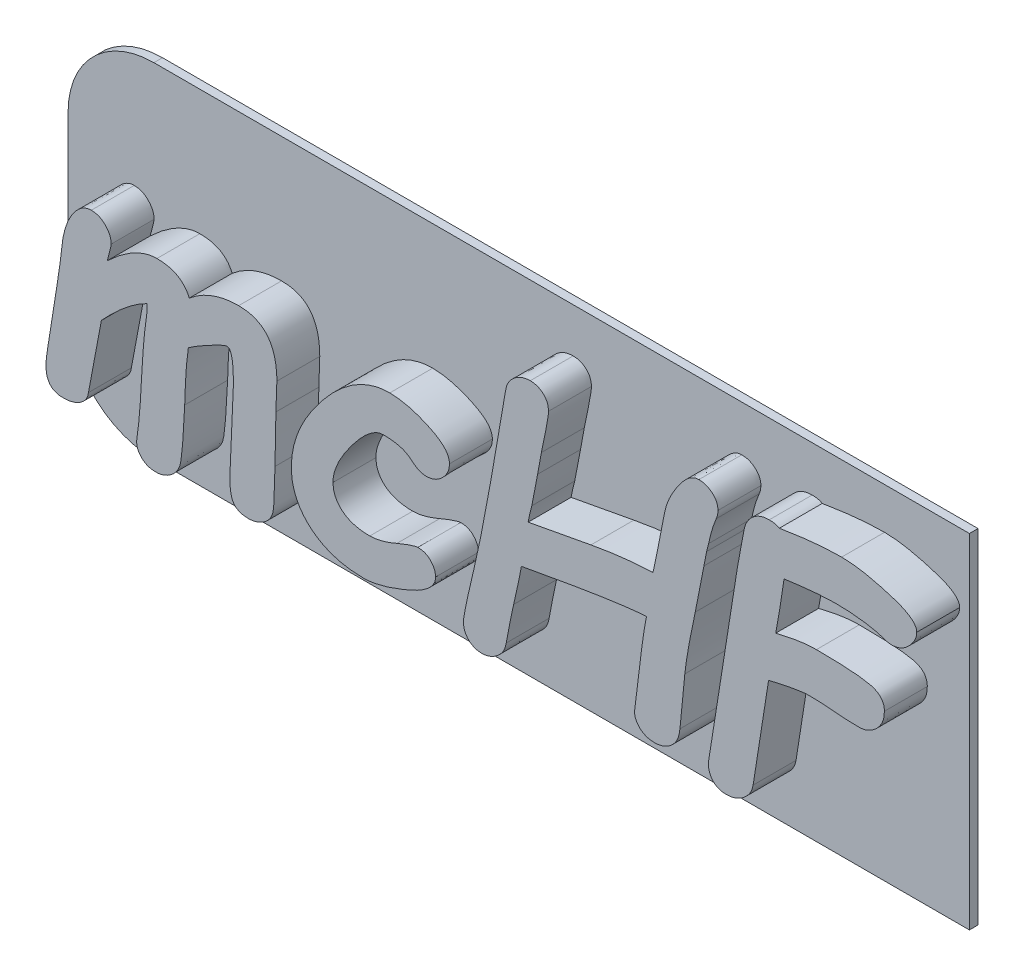
from build123d import *

# Parameters (mm, degrees)
SKETCH1_W    = 21
SKETCH1_H    = 8
BODY_DEPTH   = 0.2
TEXT_2_DEPTH = 1
FILLET1_R    = 2


with BuildPart() as part:
    # Sketch1 → body (new body)
    with BuildSketch(Plane.XY):
        Rectangle(SKETCH1_W, SKETCH1_H)
    extrude(amount=BODY_DEPTH)

    # Sketch2 → text 2 (add)
    with BuildSketch(Plane.XY.offset(0.2)):
        with BuildLine():
            add(Edge.make_bspline(
                [(-8.587596506, 0.459827581), (-8.533960483, 0.508991057), (-8.43066375, 0.603674183), (-8.274239511, 0.732043925), (-8.121054881, 0.838763403), (-7.974594097, 0.928339055), (-7.831709693, 0.996561661), (-7.694068236, 1.046427511), (-7.560444881, 1.077755316), (-7.472422593, 1.081915618), (-7.429793073, 1.083930467)],
                knots=[0, 0, 0, 0, 0.000218264, 0.000420351, 0.000606484, 0.00077796, 0.000934833, 0.00108056, 0.001216656, 0.001344467, 0.001344467, 0.001344467, 0.001344467], degree=3))
            add(Edge.make_bspline(
                [(-7.429793073, 1.083930467), (-7.383989491, 1.082729946), (-7.295919954, 1.080421626), (-7.16971868, 1.061434447), (-7.05633209, 1.02669725), (-6.953560386, 0.982440534), (-6.86544644, 0.920366349), (-6.787492259, 0.84833895), (-6.723473325, 0.760706647), (-6.692106256, 0.694936391), (-6.676077197, 0.661326768)],
                knots=[0, 0, 0, 0, 0.000137393, 0.000264174, 0.000381331, 0.000492476, 0.000598217, 0.000703005, 0.000809751, 0.000921306, 0.000921306, 0.000921306, 0.000921306], degree=3))
            add(Edge.make_bspline(
                [(-6.676077197, 0.661326768), (-6.6337414, 0.69503646), (-6.550350382, 0.76143619), (-6.417813418, 0.84841653), (-6.279663894, 0.919839221), (-6.138144648, 0.980811584), (-5.991088758, 1.025905541), (-5.840196861, 1.060523991), (-5.684348169, 1.080104581), (-5.578956204, 1.082649342), (-5.525898057, 1.083930467)],
                knots=[0, 0, 0, 0, 0.000162303, 0.000319697, 0.000474622, 0.000628367, 0.000781319, 0.000935372, 0.001092354, 0.00125151, 0.00125151, 0.00125151, 0.00125151], degree=3))
            add(Edge.make_bspline(
                [(-5.525898057, 1.083930467), (-5.489927694, 1.083029438), (-5.420319687, 1.081285811), (-5.318752211, 1.069654615), (-5.224707593, 1.047860251), (-5.136950689, 1.018251163), (-5.056586884, 0.98019667), (-4.982515924, 0.934462522), (-4.916610303, 0.878711846), (-4.856298127, 0.81573942), (-4.803732338, 0.743103659), (-4.7593999, 0.661854118), (-4.721061237, 0.572911514), (-4.689356842, 0.475648367), (-4.666027545, 0.369756795), (-4.648720706, 0.255878389), (-4.637452402, 0.133660659), (-4.636517037, 0.049230946), (-4.636034082, 0.005637523)],
                knots=[0, 0, 0, 0, 0.000107917, 0.000208836, 0.000306067, 0.000396999, 0.000486159, 0.000572288, 0.000657356, 0.000744415, 0.000833303, 0.000925447, 0.001021554, 0.001123508, 0.001231842, 0.00134645, 0.001468924, 0.001599667, 0.001599667, 0.001599667, 0.001599667], degree=3))
            add(Edge.make_bspline(
                [(-4.636034082, 0.005637523), (-4.636191976, -0.037570478), (-4.63653172, -0.130541585), (-4.641628325, -0.279025094), (-4.647744076, -0.446436146), (-4.65433711, -0.564015743), (-4.657817778, -0.626089656)],
                knots=[0, 0, 0, 0, 0.000129618, 0.000278899, 0.000445673, 0.000632181, 0.000632181, 0.000632181, 0.000632181], degree=3))
            add(Edge.make_bspline(
                [(-4.657817778, -0.626089656), (-4.658176975, -0.63661856), (-4.659254568, -0.668205272), (-4.661590874, -0.730636493), (-4.663554631, -0.823590263), (-4.665452143, -0.947042609), (-4.66911256, -1.101329509), (-4.672221671, -1.286131831), (-4.675244293, -1.501437086), (-4.678084162, -1.655007271), (-4.679601474, -1.737058144)],
                knots=[0, 0, 0, 0, 3.1605e-05, 9.4815e-05, 0.000187422, 0.000310519, 0.000465218, 0.000650408, 0.000865002, 0.001111196, 0.001111196, 0.001111196, 0.001111196], degree=3))
            add(Edge.make_bspline(
                [(-4.679601474, -1.737058144), (-4.680675305, -1.782441181), (-4.682745698, -1.869941631), (-4.685991929, -1.996651404), (-4.68938494, -2.114278776), (-4.692172696, -2.222866292), (-4.696886792, -2.321957742), (-4.701083842, -2.41164111), (-4.705711103, -2.492231461), (-4.710164913, -2.585283224), (-4.724850996, -2.689233971), (-4.763964694, -2.800726063), (-4.826637447, -2.894955207), (-4.909164587, -2.969092441), (-5.001657998, -3.025919328), (-5.09761088, -3.068047377), (-5.19680106, -3.093062485), (-5.263632276, -3.096709169), (-5.29716925, -3.098539133)],
                knots=[0, 0, 0, 0, 0.000136187, 0.000262575, 0.000380252, 0.00048922, 0.000588431, 0.000677851, 0.000758568, 0.000830586, 0.000957367, 0.001072105, 0.001182064, 0.001293064, 0.001402168, 0.001506571, 0.001606426, 0.001707009, 0.001707009, 0.001707009, 0.001707009], degree=3))
            add(Edge.make_bspline(
                [(-5.29716925, -3.098539133), (-5.333624176, -3.097390971), (-5.402008725, -3.095237172), (-5.496475267, -3.071396463), (-5.574530102, -3.03170334), (-5.638362057, -2.974082138), (-5.6824391, -2.890550477), (-5.711034713, -2.782159585), (-5.728629262, -2.646359146), (-5.730651295, -2.546383501), (-5.731753982, -2.491863204)],
                knots=[0, 0, 0, 0, 0.000109185, 0.000204816, 0.000289584, 0.000369741, 0.000458501, 0.000568466, 0.000704788, 0.000868296, 0.000868296, 0.000868296, 0.000868296], degree=3))
            Line((-5.731753982, -2.491863204), (-5.646797569, -0.537865688))
            add(Edge.make_bspline(
                [(-5.646797569, -0.537865688), (-5.647203088, -0.485943058), (-5.647963456, -0.388585701), (-5.653736042, -0.252969324), (-5.66554791, -0.138020041), (-5.681046298, -0.043976331), (-5.700989796, 0.030107313), (-5.724441385, 0.083652563), (-5.755147454, 0.120875295), (-5.781594636, 0.126234522), (-5.793837516, 0.128715405)],
                knots=[0, 0, 0, 0, 0.000155769, 0.000292074, 0.000407064, 0.000502148, 0.000578001, 0.000635974, 0.00067834, 0.000714856, 0.000714856, 0.000714856, 0.000714856], degree=3))
            add(Edge.make_bspline(
                [(-5.793837516, 0.128715405), (-5.801498336, 0.127813118), (-5.820023246, 0.125631266), (-5.852026364, 0.115859962), (-5.892877685, 0.100916957), (-5.942047562, 0.07804128), (-6.000971138, 0.051450134), (-6.068066229, 0.017114289), (-6.144680823, -0.021749803), (-6.226610938, -0.066605896), (-6.309808094, -0.111231357), (-6.38742793, -0.155585303), (-6.458480286, -0.195196271), (-6.52081654, -0.233406164), (-6.576391518, -0.267300096), (-6.623340618, -0.29856223), (-6.663720849, -0.325950923), (-6.68705516, -0.344236518), (-6.697860893, -0.352704273)],
                knots=[0, 0, 0, 0, 2.3105e-05, 5.5871e-05, 9.998e-05, 0.000153616, 0.000218429, 0.00029393, 0.000379664, 0.000476154, 0.00057412, 0.00066288, 0.000744344, 0.000818128, 0.000882205, 0.000939602, 0.00098734, 0.001028513, 0.001028513, 0.001028513, 0.001028513], degree=3))
            add(Edge.make_bspline(
                [(-6.697860893, -0.352704273), (-6.702813952, -0.381714877), (-6.713740028, -0.44571009), (-6.725994969, -0.550803657), (-6.738175565, -0.673522005), (-6.748391963, -0.814124699), (-6.7600417, -0.972700867), (-6.767627416, -1.149260444), (-6.777273931, -1.343070097), (-6.780917597, -1.478184295), (-6.782817306, -1.548629175)],
                knots=[0, 0, 0, 0, 8.8278e-05, 0.000194734, 0.00031731, 0.000458236, 0.00061763, 0.000794293, 0.000988363, 0.001199766, 0.001199766, 0.001199766, 0.001199766], degree=3))
            add(Edge.make_bspline(
                [(-6.782817306, -1.548629175), (-6.787101863, -1.636856121), (-6.795196146, -1.803532353), (-6.80771807, -2.038862937), (-6.822234269, -2.244680805), (-6.835624582, -2.421250285), (-6.851015639, -2.568276325), (-6.865573052, -2.686487329), (-6.880888937, -2.775366773), (-6.901736736, -2.854702479), (-6.937674171, -2.928899108), (-6.987416191, -3.006216146), (-7.050130497, -3.073746394), (-7.122025444, -3.131733589), (-7.201178225, -3.178233709), (-7.284209095, -3.212814346), (-7.370602497, -3.234436641), (-7.429671937, -3.23678222), (-7.459201062, -3.237954787)],
                knots=[0, 0, 0, 0, 0.000264994, 0.000500621, 0.000706963, 0.000883979, 0.001031807, 0.001150423, 0.001241218, 0.001302261, 0.00139583, 0.001487062, 0.001577254, 0.001670981, 0.00176326, 0.001851652, 0.001940151, 0.002028617, 0.002028617, 0.002028617, 0.002028617], degree=3))
            add(Edge.make_bspline(
                [(-7.459201062, -3.237954787), (-7.490910859, -3.236516366), (-7.551875278, -3.233750896), (-7.638789715, -3.211879802), (-7.715495972, -3.173784432), (-7.782117577, -3.122949385), (-7.834913024, -3.060531035), (-7.875839605, -2.992239846), (-7.899207313, -2.916666113), (-7.902120155, -2.864513162), (-7.903588457, -2.838223968)],
                knots=[0, 0, 0, 0, 9.5065e-05, 0.00018277, 0.000266552, 0.000350427, 0.000432297, 0.000510385, 0.000587901, 0.000666692, 0.000666692, 0.000666692, 0.000666692], degree=3))
            Line((-7.903588457, -2.838223968), (-7.852396772, -2.430868856))
            add(Edge.make_bspline(
                [(-7.852396772, -2.430868856), (-7.849885494, -2.406177903), (-7.844493742, -2.353166059), (-7.835191178, -2.268330015), (-7.828107105, -2.172027501), (-7.820506404, -2.065287534), (-7.812802216, -1.947657425), (-7.805266794, -1.819489961), (-7.797629926, -1.680073563), (-7.792812338, -1.583485277), (-7.790313239, -1.533380588)],
                knots=[0, 0, 0, 0, 7.4456e-05, 0.000159858, 0.000256009, 0.000364108, 0.000480899, 0.000609649, 0.000749273, 0.000899774, 0.000899774, 0.000899774, 0.000899774], degree=3))
            add(Edge.make_bspline(
                [(-7.790313239, -1.533380588), (-7.786367384, -1.463307202), (-7.778801686, -1.328949965), (-7.767139855, -1.135387263), (-7.753911658, -0.958604328), (-7.740843034, -0.797764718), (-7.727945574, -0.653240513), (-7.714872013, -0.525076484), (-7.702388104, -0.413101522), (-7.691769246, -0.34432561), (-7.686840684, -0.312404436)],
                knots=[0, 0, 0, 0, 0.000210554, 0.000403711, 0.000581729, 0.000742372, 0.000887822, 0.001017008, 0.001128872, 0.00122576, 0.00122576, 0.00122576, 0.00122576], degree=3))
            add(Edge.make_bspline(
                [(-7.686840684, -0.312404436), (-7.681462141, -0.276498825), (-7.671218037, -0.208112118), (-7.661237987, -0.110396952), (-7.657031926, -0.022656168), (-7.660267785, 0.032147294), (-7.661789433, 0.057918393)],
                knots=[0, 0, 0, 0, 0.000108902, 0.000207418, 0.000294614, 0.000372015, 0.000372015, 0.000372015, 0.000372015], degree=3))
            add(Edge.make_bspline(
                [(-7.661789433, 0.057918393), (-7.703153497, 0.036362385), (-7.788666315, -0.008200814), (-7.913959189, -0.088671696), (-8.043493559, -0.179195829), (-8.174388167, -0.282949881), (-8.308767474, -0.397403105), (-8.445220181, -0.524404098), (-8.584113913, -0.663762995), (-8.676433831, -0.761998134), (-8.723744605, -0.812340255)],
                knots=[0, 0, 0, 0, 0.000139866, 0.000289148, 0.000446281, 0.000613839, 0.000789984, 0.000975724, 0.001172888, 0.001380134, 0.001380134, 0.001380134, 0.001380134], degree=3))
            Line((-8.723744605, -0.812340255), (-9.025448793, -2.419977008))
            add(Edge.make_bspline(
                [(-9.025448793, -2.419977008), (-9.030493929, -2.449115289), (-9.040495819, -2.5068814), (-9.081954182, -2.5856556), (-9.140632523, -2.654984549), (-9.215753477, -2.713905359), (-9.303840453, -2.761653401), (-9.402225532, -2.79509186), (-9.508483144, -2.816529877), (-9.582277751, -2.818630131), (-9.620143689, -2.819707827)],
                knots=[0, 0, 0, 0, 8.8251e-05, 0.000174956, 0.000263092, 0.0003592, 0.0004596, 0.00056225, 0.000669908, 0.000783372, 0.000783372, 0.000783372, 0.000783372], degree=3))
            add(Edge.make_bspline(
                [(-9.620143689, -2.819707827), (-9.651191974, -2.818891048), (-9.709819278, -2.817348757), (-9.79129835, -2.79416869), (-9.86191805, -2.760363166), (-9.918222264, -2.708440645), (-9.96251898, -2.644227488), (-9.992872452, -2.565167575), (-10.010968768, -2.473078996), (-10.01323183, -2.406997911), (-10.014428584, -2.372052877)],
                knots=[0, 0, 0, 0, 9.2811e-05, 0.000175252, 0.000252215, 0.000325482, 0.000402221, 0.000484338, 0.000577684, 0.00068245, 0.00068245, 0.00068245, 0.00068245], degree=3))
            add(Edge.make_bspline(
                [(-10.014428584, -2.372052877), (-10.014137184, -2.344434752), (-10.013514733, -2.285440474), (-10.003151162, -2.192975658), (-9.992264213, -2.090276149), (-9.979675456, -2.019456033), (-9.973039562, -1.982124722)],
                knots=[0, 0, 0, 0, 8.2807e-05, 0.000176881, 0.000278881, 0.000392585, 0.000392585, 0.000392585, 0.000392585], degree=3))
            Line((-9.973039562, -1.982124722), (-9.763916082, -0.657676015))
            add(Edge.make_bspline(
                [(-9.763916082, -0.657676015), (-9.751379334, -0.577831014), (-9.727405732, -0.425146092), (-9.696220448, -0.206881727), (-9.669067685, -0.010250763), (-9.655804959, 0.113795749), (-9.649551678, 0.172282796)],
                knots=[0, 0, 0, 0, 0.000242465, 0.000463658, 0.000661447, 0.000837898, 0.000837898, 0.000837898, 0.000837898], degree=3))
            add(Edge.make_bspline(
                [(-9.649551678, 0.172282796), (-9.645159982, 0.21407405), (-9.636544565, 0.296058115), (-9.61838704, 0.415412642), (-9.594481675, 0.528189962), (-9.564882624, 0.633880281), (-9.531486693, 0.73296028), (-9.493082495, 0.825484323), (-9.449899546, 0.911126873), (-9.401978173, 0.989692979), (-9.350849347, 1.059891619), (-9.299523135, 1.122544047), (-9.244828518, 1.173937856), (-9.19136428, 1.218407532), (-9.134451522, 1.251538408), (-9.077039271, 1.275584093), (-9.018239504, 1.290782948), (-8.97870089, 1.292298914), (-8.95900852, 1.293053947)],
                knots=[0, 0, 0, 0, 0.000126054, 0.000247287, 0.000362003, 0.000471671, 0.00057638, 0.000675496, 0.000771942, 0.000863848, 0.000951214, 0.001032378, 0.00110633, 0.001176072, 0.001240519, 0.001303021, 0.001362459, 0.001421436, 0.001421436, 0.001421436, 0.001421436], degree=3))
            add(Edge.make_bspline(
                [(-8.95900852, 1.293053947), (-8.927586332, 1.2914853), (-8.866126653, 1.288417133), (-8.778097864, 1.261046661), (-8.69794561, 1.216603189), (-8.628418232, 1.155478918), (-8.570323632, 1.085262299), (-8.527495956, 1.008213207), (-8.501255669, 0.926223779), (-8.4978286, 0.869547251), (-8.496104984, 0.841042259)],
                knots=[0, 0, 0, 0, 9.4074e-05, 0.000184003, 0.000273714, 0.000367162, 0.000460043, 0.00054584, 0.000630243, 0.000715645, 0.000715645, 0.000715645, 0.000715645], degree=3))
            add(Edge.make_bspline(
                [(-8.496104984, 0.841042259), (-8.49635826, 0.835583955), (-8.497004848, 0.821649443), (-8.502181922, 0.796270225), (-8.509711505, 0.762224464), (-8.519561836, 0.718928389), (-8.532884492, 0.667163761), (-8.547976196, 0.605674433), (-8.566296238, 0.535543067), (-8.580249307, 0.485944473), (-8.587596506, 0.459827581)],
                knots=[0, 0, 0, 0, 1.6374e-05, 4.1801e-05, 7.7479e-05, 0.000121074, 0.000174964, 0.000237835, 0.000311014, 0.000392404, 0.000392404, 0.000392404, 0.000392404], degree=3))
        make_face()
        with BuildLine():
            add(Edge.make_bspline(
                [(-4.298386796, -1.555164283), (-4.295965927, -1.48603896), (-4.291069107, -1.346215528), (-4.254162554, -1.135685081), (-4.196302677, -0.92223845), (-4.113926679, -0.70605603), (-4.007088169, -0.488283843), (-3.87899783, -0.267120041), (-3.726953918, -0.043861526), (-3.55489563, 0.176649019), (-3.371595514, 0.385805122), (-3.182707998, 0.571802238), (-2.990932895, 0.728957626), (-2.798335307, 0.858794732), (-2.602814257, 0.959452302), (-2.405263507, 1.030921842), (-2.205517902, 1.075618212), (-2.071224938, 1.081173095), (-2.004563625, 1.083930467)],
                knots=[0, 0, 0, 0, 0.000207292, 0.0004193, 0.000639396, 0.000870007, 0.001112113, 0.001366369, 0.00163614, 0.001921768, 0.002204975, 0.002469931, 0.002716082, 0.002947782, 0.003165524, 0.003373968, 0.0035767, 0.003776523, 0.003776523, 0.003776523, 0.003776523], degree=3))
            add(Edge.make_bspline(
                [(-2.004563625, 1.083930467), (-1.934675719, 1.080929956), (-1.790141105, 1.074724623), (-1.569121355, 1.03079922), (-1.338361007, 0.960374449), (-1.144879424, 0.880083257), (-0.993601053, 0.807726787), (-0.893621012, 0.748350498), (-0.808419089, 0.688199819), (-0.738201859, 0.625317406), (-0.682640449, 0.560325145), (-0.644043607, 0.491798866), (-0.619031884, 0.421230603), (-0.616186246, 0.372892786), (-0.614763831, 0.348730733)],
                knots=[0, 0, 0, 0, 0.000209602, 0.000433477, 0.000673634, 0.00093253, 0.001061128, 0.001176381, 0.001280965, 0.001373501, 0.001458569, 0.001536116, 0.001608446, 0.001680736, 0.001680736, 0.001680736, 0.001680736], degree=3))
            add(Edge.make_bspline(
                [(-0.614763831, 0.348730733), (-0.61653233, 0.316523197), (-0.620071024, 0.252077272), (-0.653014375, 0.158275098), (-0.705135837, 0.068858543), (-0.776600759, -0.012561058), (-0.859032283, -0.084982745), (-0.954433633, -0.135235983), (-1.055759562, -0.169306924), (-1.126765539, -0.172477046), (-1.162623781, -0.174077967)],
                knots=[0, 0, 0, 0, 9.6348e-05, 0.000192789, 0.000294789, 0.000405249, 0.000516538, 0.000621806, 0.000726871, 0.000834061, 0.000834061, 0.000834061, 0.000834061], degree=3))
            add(Edge.make_bspline(
                [(-1.162623781, -0.174077967), (-1.190808921, -0.171630087), (-1.249760746, -0.166510118), (-1.338430513, -0.133790615), (-1.428278462, -0.079962863), (-1.485258284, -0.033302627), (-1.515519653, -0.008521879)],
                knots=[0, 0, 0, 0, 8.4572e-05, 0.000176889, 0.000280379, 0.000397592, 0.000397592, 0.000397592, 0.000397592], degree=3))
            add(Edge.make_bspline(
                [(-1.515519653, -0.008521879), (-1.532620552, 0.005367968), (-1.5680624, 0.034154869), (-1.629049221, 0.069389399), (-1.697777202, 0.099258376), (-1.774364145, 0.122378563), (-1.858201926, 0.14268162), (-1.95057968, 0.154590966), (-2.050109758, 0.164156214), (-2.119263707, 0.164487779), (-2.154871126, 0.164658503)],
                knots=[0, 0, 0, 0, 6.601e-05, 0.000136807, 0.000210462, 0.000290382, 0.00037651, 0.000468931, 0.000569514, 0.000676276, 0.000676276, 0.000676276, 0.000676276], degree=3))
            add(Edge.make_bspline(
                [(-2.154871126, 0.164658503), (-2.180509361, 0.162918905), (-2.234226275, 0.15927412), (-2.315461298, 0.128894516), (-2.400287518, 0.082440708), (-2.490513139, 0.018003161), (-2.583936562, -0.06505867), (-2.683000662, -0.165392206), (-2.785490877, -0.284247623), (-2.89019214, -0.416486566), (-2.990141574, -0.554583988), (-3.07975361, -0.690753372), (-3.156171065, -0.820514593), (-3.21823319, -0.944930397), (-3.265928885, -1.063074516), (-3.301840133, -1.174904797), (-3.323983519, -1.281259651), (-3.32664076, -1.350666483), (-3.327923147, -1.384162271)],
                knots=[0, 0, 0, 0, 7.6739e-05, 0.000160783, 0.000257273, 0.000366669, 0.000492493, 0.000631896, 0.00078938, 0.000963056, 0.001137788, 0.001300617, 0.001451931, 0.001589294, 0.001717323, 0.001833758, 0.001941417, 0.002041835, 0.002041835, 0.002041835, 0.002041835], degree=3))
            add(Edge.make_bspline(
                [(-3.327923147, -1.384162271), (-3.325417729, -1.43027969), (-3.320529175, -1.520263668), (-3.275645198, -1.647775505), (-3.204102716, -1.761853684), (-3.104418576, -1.860495594), (-2.979189061, -1.940548115), (-2.828944274, -1.99513164), (-2.657573552, -2.030884302), (-2.535200245, -2.033904012), (-2.470734716, -2.035494777)],
                knots=[0, 0, 0, 0, 0.000137966, 0.000269198, 0.000400353, 0.000538984, 0.000686426, 0.000842591, 0.001016041, 0.001209135, 0.001209135, 0.001209135, 0.001209135], degree=3))
            add(Edge.make_bspline(
                [(-2.470734716, -2.035494777), (-2.426314273, -2.032923265), (-2.330795294, -2.027393646), (-2.180259831, -1.994926809), (-2.013754676, -1.941587926), (-1.899656196, -1.894094482), (-1.839007537, -1.868849503)],
                knots=[0, 0, 0, 0, 0.000133326, 0.000286696, 0.000460311, 0.000657309, 0.000657309, 0.000657309, 0.000657309], degree=3))
            add(Edge.make_bspline(
                [(-1.839007537, -1.868849503), (-1.807426063, -1.856129214), (-1.747577593, -1.832023631), (-1.662822244, -1.798116329), (-1.587470105, -1.769260139), (-1.521355476, -1.747165169), (-1.465470465, -1.727696008), (-1.418586441, -1.714633509), (-1.381123515, -1.706164592), (-1.359066202, -1.704903167), (-1.349963565, -1.7043826)],
                knots=[0, 0, 0, 0, 0.00010214, 0.00019356, 0.000273872, 0.000344139, 0.000402692, 0.000451317, 0.000490193, 0.00051751, 0.00051751, 0.00051751, 0.00051751], degree=3))
            add(Edge.make_bspline(
                [(-1.349963565, -1.7043826), (-1.321132502, -1.70580763), (-1.265486632, -1.708558034), (-1.185952519, -1.730993672), (-1.114569458, -1.768784058), (-1.053326278, -1.82136399), (-1.002728702, -1.882192742), (-0.965191029, -1.949617172), (-0.942895682, -2.022124585), (-0.939802613, -2.072379786), (-0.938251714, -2.09757831)],
                knots=[0, 0, 0, 0, 8.6383e-05, 0.000166724, 0.000245658, 0.000326823, 0.00040729, 0.000481873, 0.000556987, 0.000632527, 0.000632527, 0.000632527, 0.000632527], degree=3))
            add(Edge.make_bspline(
                [(-0.938251714, -2.09757831), (-0.940139806, -2.123645874), (-0.94401688, -2.177173893), (-0.977459419, -2.255354333), (-1.030194231, -2.330881238), (-1.1025541, -2.405917016), (-1.196172339, -2.477407457), (-1.308063582, -2.550382347), (-1.44192803, -2.618521181), (-1.58996003, -2.686143851), (-1.743993818, -2.748574225), (-1.894003116, -2.80342571), (-2.034608388, -2.852885947), (-2.167420472, -2.889862539), (-2.290827406, -2.922033595), (-2.406411305, -2.941844087), (-2.513213379, -2.956359215), (-2.58178886, -2.958230612), (-2.614507108, -2.95912348)],
                knots=[0, 0, 0, 0, 7.7951e-05, 0.000160067, 0.000250999, 0.000353458, 0.000471342, 0.000603668, 0.000753722, 0.000921386, 0.001091891, 0.001252135, 0.001400588, 0.001538829, 0.001665629, 0.001782922, 0.00189046, 0.001988583, 0.001988583, 0.001988583, 0.001988583], degree=3))
            add(Edge.make_bspline(
                [(-2.614507108, -2.95912348), (-2.676263569, -2.957719996), (-2.79711984, -2.954973404), (-2.974194083, -2.937846362), (-3.141759405, -2.907531579), (-3.299931826, -2.864921262), (-3.448651306, -2.810286022), (-3.588926743, -2.744222196), (-3.71860738, -2.664021276), (-3.838512285, -2.573936287), (-3.946739232, -2.473993621), (-4.040278511, -2.364599519), (-4.121124856, -2.248792996), (-4.18520625, -2.12418382), (-4.237233125, -1.993147264), (-4.27301472, -1.853740107), (-4.293663601, -1.706819166), (-4.29679041, -1.606421905), (-4.298386796, -1.555164283)],
                knots=[0, 0, 0, 0, 0.000185277, 0.000362583, 0.000533068, 0.000695561, 0.000853383, 0.001007821, 0.001159879, 0.001309969, 0.00145717, 0.001600827, 0.001741011, 0.001879855, 0.002020225, 0.002163145, 0.002310555, 0.002464319, 0.002464319, 0.002464319, 0.002464319], degree=3))
        make_face()
        with BuildLine():
            add(Edge.make_bspline(
                [(3.976150067, -0.437660687), (3.946376338, -0.439421191), (3.882802102, -0.443180301), (3.781024064, -0.450402592), (3.667150501, -0.463164709), (3.540451709, -0.477354642), (3.401211646, -0.493000491), (3.2500253, -0.514632224), (3.086520761, -0.536968872), (2.910842242, -0.563453736), (2.722393012, -0.592753682), (2.521722946, -0.625708884), (2.308389815, -0.660014458), (2.08318489, -0.700015492), (1.845323235, -0.741070633), (1.594641726, -0.784423857), (1.332338243, -0.832689135), (1.152987784, -0.865373862), (1.061491564, -0.882048082)],
                knots=[0, 0, 0, 0, 8.9479e-05, 0.00019106, 0.00030605, 0.000433186, 0.000573556, 0.000726361, 0.000891332, 0.001068628, 0.001259338, 0.001463469, 0.001678701, 0.001907547, 0.002149642, 0.002402842, 0.002670746, 0.002949756, 0.002949756, 0.002949756, 0.002949756], degree=3))
            add(Edge.make_bspline(
                [(1.061491564, -0.882048082), (1.056830823, -0.908562428), (1.047053906, -0.964182036), (1.030414389, -1.051625099), (1.012365351, -1.147279921), (0.99013956, -1.250593537), (0.966162826, -1.362049149), (0.940046957, -1.481502129), (0.912026371, -1.609089679), (0.89134234, -1.696424197), (0.880686889, -1.741414883)],
                knots=[0, 0, 0, 0, 8.0761e-05, 0.000169415, 0.000267035, 0.000372776, 0.000486427, 0.000609056, 0.000739599, 0.000878303, 0.000878303, 0.000878303, 0.000878303], degree=3))
            add(Edge.make_bspline(
                [(0.880686889, -1.741414883), (0.870505288, -1.789698944), (0.850905992, -1.882644406), (0.822907314, -2.016678812), (0.795656116, -2.139748291), (0.775047735, -2.253477132), (0.753689086, -2.355951129), (0.736563116, -2.448296922), (0.720774724, -2.529827166), (0.712474039, -2.581155959), (0.708595691, -2.605138423)],
                knots=[0, 0, 0, 0, 0.000148037, 0.000284967, 0.00041079, 0.000526141, 0.000631663, 0.000724799, 0.000807899, 0.000880777, 0.000880777, 0.000880777, 0.000880777], degree=3))
            add(Edge.make_bspline(
                [(0.708595691, -2.605138423), (0.701871058, -2.639256399), (0.688687698, -2.706143248), (0.646933121, -2.800681939), (0.585753891, -2.884754555), (0.50993739, -2.958930332), (0.42431047, -3.020916868), (0.331032544, -3.064633685), (0.234378, -3.093889915), (0.16784028, -3.096990136), (0.134595306, -3.098539133)],
                knots=[0, 0, 0, 0, 0.00010409, 0.000204064, 0.000307128, 0.000414185, 0.000521175, 0.00062251, 0.000722151, 0.000821649, 0.000821649, 0.000821649, 0.000821649], degree=3))
            add(Edge.make_bspline(
                [(0.134595306, -3.098539133), (0.104652231, -3.097223001), (0.046722138, -3.094676714), (-0.035387848, -3.0707688), (-0.109173418, -3.03339073), (-0.172527514, -2.98067678), (-0.222860209, -2.916614201), (-0.261556581, -2.845514041), (-0.283585927, -2.766529496), (-0.286511296, -2.711646716), (-0.288008393, -2.683559728)],
                knots=[0, 0, 0, 0, 8.9638e-05, 0.00017342, 0.000254284, 0.000336285, 0.000418444, 0.000497378, 0.00057772, 0.000661933, 0.000661933, 0.000661933, 0.000661933], degree=3))
            add(Edge.make_bspline(
                [(-0.288008393, -2.683559728), (-0.287251203, -2.665010169), (-0.285370526, -2.618937587), (-0.27093055, -2.537147999), (-0.253672087, -2.428276728), (-0.224895449, -2.29324107), (-0.19169387, -2.130777248), (-0.150417125, -1.941491397), (-0.099500051, -1.725821574), (-0.06395158, -1.572965382), (-0.045120184, -1.491991565)],
                knots=[0, 0, 0, 0, 5.5644e-05, 0.000138207, 0.000248688, 0.000386465, 0.000552229, 0.000746214, 0.000967616, 0.00121702, 0.00121702, 0.00121702, 0.00121702], degree=3))
            add(Edge.make_bspline(
                [(-0.045120184, -1.491991565), (-0.035663297, -1.452059311), (-0.015388833, -1.366449218), (0.016566501, -1.229811342), (0.048518334, -1.075551734), (0.084938801, -0.90472583), (0.122819295, -0.716241255), (0.163098943, -0.510741774), (0.205217838, -0.288046559), (0.251761968, -0.048710355), (0.297602564, 0.208656933), (0.348544549, 0.482485822), (0.398935195, 0.773935059), (0.453888632, 1.082022622), (0.510470281, 1.40770079), (0.568744095, 1.750586284), (0.631681599, 2.110110823), (0.672475817, 2.355703517), (0.693347104, 2.481354555)],
                knots=[0, 0, 0, 0, 0.000123112, 0.000263937, 0.00042095, 0.000595688, 0.000787935, 0.000997698, 0.001223916, 0.001467864, 0.001729144, 0.002008154, 0.002303437, 0.00261645, 0.002947005, 0.003295103, 0.003659856, 0.004041973, 0.004041973, 0.004041973, 0.004041973], degree=3))
            add(Edge.make_bspline(
                [(0.693347104, 2.481354555), (0.699621393, 2.514787613), (0.712000797, 2.580752276), (0.754299045, 2.672963323), (0.812370676, 2.756579817), (0.887044341, 2.828946542), (0.971611966, 2.889538546), (1.064773108, 2.934025478), (1.164165585, 2.96119678), (1.232687985, 2.964414316), (1.26734749, 2.966041787)],
                knots=[0, 0, 0, 0, 0.000101721, 0.000200699, 0.000301618, 0.000405593, 0.000511064, 0.0006124, 0.000713852, 0.000817691, 0.000817691, 0.000817691, 0.000817691], degree=3))
            add(Edge.make_bspline(
                [(1.26734749, 2.966041787), (1.296920088, 2.965081679), (1.354402513, 2.963215445), (1.435858205, 2.940258056), (1.510166953, 2.905271933), (1.573770325, 2.854509614), (1.627437263, 2.794665793), (1.665688545, 2.724194661), (1.689108915, 2.646214686), (1.691829169, 2.591164462), (1.693218743, 2.563043414)],
                knots=[0, 0, 0, 0, 8.8466e-05, 0.000171957, 0.000251847, 0.000333333, 0.00041438, 0.000491397, 0.000572041, 0.000656254, 0.000656254, 0.000656254, 0.000656254], degree=3))
            add(Edge.make_bspline(
                [(1.693218743, 2.563043414), (1.692693293, 2.548504851), (1.691401368, 2.512758886), (1.682567543, 2.449246746), (1.66971169, 2.365709907), (1.650350296, 2.261702678), (1.628154851, 2.136982997), (1.599353717, 1.99183951), (1.565786933, 1.826603236), (1.540842015, 1.709826062), (1.527662655, 1.648128189)],
                knots=[0, 0, 0, 0, 4.3622e-05, 0.000107253, 0.000192133, 0.000297249, 0.000424576, 0.00057218, 0.000741144, 0.000930412, 0.000930412, 0.000930412, 0.000930412], degree=3))
            Line((1.527662655, 1.648128189), (1.439438687, 1.164530142))
            add(Edge.make_bspline(
                [(1.439438687, 1.164530142), (1.427267128, 1.094428006), (1.404290623, 0.962094737), (1.369140329, 0.775163826), (1.336993884, 0.610935475), (1.314708237, 0.509169993), (1.304379773, 0.462005951)],
                knots=[0, 0, 0, 0, 0.00021345, 0.000402933, 0.000570615, 0.000715456, 0.000715456, 0.000715456, 0.000715456], degree=3))
            add(Edge.make_bspline(
                [(1.304379773, 0.462005951), (1.287190174, 0.397573716), (1.254246483, 0.274089989), (1.230688897, 0.148482615), (1.219423359, 0.088415567)],
                knots=[0, 0, 0, 0, 0.000199974, 0.000383249, 0.000383249, 0.000383249, 0.000383249], degree=3))
            Line((1.219423359, 0.088415567), (2.682198534, 0.360711765))
            add(Edge.make_bspline(
                [(2.682198534, 0.360711765), (2.805838254, 0.382832539), (3.050250908, 0.42656118), (3.415675367, 0.472939431), (3.773677058, 0.509743797), (4.010563511, 0.520805284), (4.127546753, 0.526267854)],
                knots=[0, 0, 0, 0, 0.000376746, 0.000744757, 0.00110479, 0.001456055, 0.001456055, 0.001456055, 0.001456055], degree=3))
            add(Edge.make_bspline(
                [(4.127546753, 0.526267854), (4.133494776, 0.551288614), (4.147331545, 0.609493913), (4.167235735, 0.710394564), (4.193465702, 0.8363537), (4.225709987, 0.98783453), (4.259661204, 1.165699711), (4.300404598, 1.368854077), (4.344875812, 1.597620537), (4.37590278, 1.758494762), (4.392218657, 1.843092267)],
                knots=[0, 0, 0, 0, 7.7148e-05, 0.000179467, 0.000308489, 0.000463145, 0.000644071, 0.000851697, 0.001084745, 0.001343215, 0.001343215, 0.001343215, 0.001343215], degree=3))
            add(Edge.make_bspline(
                [(4.392218657, 1.843092267), (4.403875239, 1.899027805), (4.428109146, 2.015317187), (4.494906278, 2.189936949), (4.587963121, 2.370500432), (4.681523747, 2.522909269), (4.765920869, 2.640047636), (4.829512159, 2.718660621), (4.892406239, 2.785046879), (4.954078256, 2.840355104), (5.01618863, 2.882458273), (5.076587691, 2.913578455), (5.137245788, 2.932193392), (5.17740661, 2.935171499), (5.197126218, 2.936633798)],
                knots=[0, 0, 0, 0, 0.000171196, 0.000355915, 0.00055855, 0.000780108, 0.000891657, 0.000991512, 0.001083192, 0.001165776, 0.001239488, 0.001307681, 0.001369025, 0.001428203, 0.001428203, 0.001428203, 0.001428203], degree=3))
            add(Edge.make_bspline(
                [(5.197126218, 2.936633798), (5.226669857, 2.935152941), (5.284419513, 2.932258276), (5.367813703, 2.909920993), (5.444142259, 2.872117699), (5.511741263, 2.820969381), (5.570129875, 2.761447613), (5.610960354, 2.691714251), (5.637893858, 2.616538205), (5.640298465, 2.563636455), (5.641513613, 2.536902979)],
                knots=[0, 0, 0, 0, 8.8553e-05, 0.000173096, 0.000256879, 0.000342489, 0.000426469, 0.000505109, 0.000583296, 0.000663171, 0.000663171, 0.000663171, 0.000663171], degree=3))
            add(Edge.make_bspline(
                [(5.641513613, 2.536902979), (5.639822714, 2.50534443), (5.636363211, 2.44077706), (5.613104396, 2.380419719), (5.601213776, 2.349563195)],
                knots=[0, 0, 0, 0, 9.4181e-05, 0.000192691, 0.000192691, 0.000192691, 0.000192691], degree=3))
            add(Edge.make_bspline(
                [(5.601213776, 2.349563195), (5.583493181, 2.306961999), (5.546712577, 2.218539589), (5.502718794, 2.076225469), (5.458993713, 1.922661652), (5.436434159, 1.814940758), (5.42476584, 1.759225038)],
                knots=[0, 0, 0, 0, 0.000138344, 0.000287144, 0.000446485, 0.000617196, 0.000617196, 0.000617196, 0.000617196], degree=3))
            add(Edge.make_bspline(
                [(5.42476584, 1.759225038), (5.418102838, 1.7301199), (5.403792578, 1.667610219), (5.386228028, 1.605933732), (5.376841709, 1.572974439)],
                knots=[0, 0, 0, 0, 8.9559e-05, 0.000192347, 0.000192347, 0.000192347, 0.000192347], degree=3))
            add(Edge.make_bspline(
                [(5.376841709, 1.572974439), (5.368385382, 1.533785648), (5.353290674, 1.463832903), (5.334779875, 1.371607358), (5.322303535, 1.304442575), (5.31687122, 1.268013394), (5.314758176, 1.253843295)],
                knots=[0, 0, 0, 0, 0.00012027, 0.000214684, 0.000282196, 0.000325174, 0.000325174, 0.000325174, 0.000325174], degree=3))
            add(Edge.make_bspline(
                [(5.314758176, 1.253843295), (5.311091111, 1.233518512), (5.30258069, 1.186349334), (5.289034317, 1.10550197), (5.268450203, 1.005616176), (5.246353522, 0.885950669), (5.218555567, 0.747006994), (5.187336608, 0.588639326), (5.15117104, 0.410782764), (5.125617548, 0.285918049), (5.112169805, 0.220206927)],
                knots=[0, 0, 0, 0, 6.1959e-05, 0.000143793, 0.000245898, 0.000367872, 0.000508853, 0.000670981, 0.00085212, 0.001053339, 0.001053339, 0.001053339, 0.001053339], degree=3))
            add(Edge.make_bspline(
                [(5.112169805, 0.220206927), (5.096151911, 0.143973193), (5.065273248, -0.002987182), (5.021399968, -0.215247894), (4.983260158, -0.411309939), (4.950453316, -0.590656236), (4.923412181, -0.75341088), (4.900016397, -0.899241944), (4.882582673, -1.028938312), (4.873508296, -1.110035426), (4.869281596, -1.147809171)],
                knots=[0, 0, 0, 0, 0.000233696, 0.000450509, 0.000650234, 0.000832896, 0.000997453, 0.001145185, 0.001275964, 0.001389991, 0.001389991, 0.001389991, 0.001389991], degree=3))
            Line((4.869281596, -1.147809171), (4.756006378, -2.313236898))
            add(Edge.make_bspline(
                [(4.756006378, -2.313236898), (4.750660405, -2.356394913), (4.740391831, -2.439293056), (4.700290932, -2.55527893), (4.640912665, -2.656388264), (4.562829686, -2.739867764), (4.473548191, -2.80691571), (4.374656944, -2.854339658), (4.268289325, -2.883897278), (4.194542995, -2.887552566), (4.156954742, -2.889415653)],
                knots=[0, 0, 0, 0, 0.000130179, 0.000250049, 0.000365302, 0.000479381, 0.000590696, 0.000698355, 0.000806684, 0.000919297, 0.000919297, 0.000919297, 0.000919297], degree=3))
            add(Edge.make_bspline(
                [(4.156954742, -2.889415653), (4.12487193, -2.888002093), (4.063172408, -2.885283629), (3.974709303, -2.862906833), (3.895312315, -2.825387041), (3.825640344, -2.774459807), (3.76947238, -2.712917093), (3.727748383, -2.644672688), (3.701100376, -2.570749497), (3.698582288, -2.518946259), (3.69731876, -2.492952389)],
                knots=[0, 0, 0, 0, 9.6151e-05, 0.000184911, 0.000271637, 0.000358122, 0.000442159, 0.000519866, 0.000597022, 0.000674729, 0.000674729, 0.000674729, 0.000674729], degree=3))
            Line((3.69731876, -2.492952389), (3.862874848, -1.145630802))
            add(Edge.make_bspline(
                [(3.862874848, -1.145630802), (3.866318712, -1.113658129), (3.872902609, -1.052533531), (3.885247198, -0.965479786), (3.896833654, -0.887347213), (3.90560766, -0.838462847), (3.909709795, -0.81560781)],
                knots=[0, 0, 0, 0, 9.6465e-05, 0.00018442, 0.000263751, 0.000333408, 0.000333408, 0.000333408, 0.000333408], degree=3))
            Line((3.909709795, -0.81560781), (3.943474523, -0.614108623))
            add(Edge.make_bspline(
                [(3.943474523, -0.614108623), (3.947761847, -0.583894176), (3.956173014, -0.524617401), (3.969577896, -0.466268229), (3.976150067, -0.437660687)],
                knots=[0, 0, 0, 0, 9.1504e-05, 0.00017952, 0.00017952, 0.00017952, 0.00017952], degree=3))
        make_face()
        with BuildLine():
            add(Edge.make_bspline(
                [(7.181620909, 1.924781126), (7.172373424, 1.860127067), (7.154488397, 1.73508338), (7.12546955, 1.55449501), (7.099623101, 1.38629581), (7.074791337, 1.230864671), (7.050329104, 1.088326709), (7.029308461, 0.958088491), (7.007018494, 0.841035447), (6.993173541, 0.766980743), (6.986656831, 0.732123779)],
                knots=[0, 0, 0, 0, 0.000195932, 0.000378941, 0.0005487, 0.000706456, 0.000851137, 0.000982568, 0.0011022, 0.001208583, 0.001208583, 0.001208583, 0.001208583], degree=3))
            add(Edge.make_bspline(
                [(6.986656831, 0.732123779), (7.076860012, 0.753774953), (7.249215263, 0.795144819), (7.498312269, 0.839233161), (7.724395483, 0.869237737), (7.867726415, 0.873021945), (7.935336785, 0.874806987)],
                knots=[0, 0, 0, 0, 0.000278222, 0.000531612, 0.000758711, 0.000961487, 0.000961487, 0.000961487, 0.000961487], degree=3))
            add(Edge.make_bspline(
                [(7.935336785, 0.874806987), (8.002865904, 0.874567807), (8.133212901, 0.874106132), (8.321694912, 0.871436392), (8.495558256, 0.86406607), (8.654714375, 0.857653572), (8.798759817, 0.845808758), (8.928241825, 0.835023676), (9.042981555, 0.819393005), (9.143872926, 0.802533452), (9.232442911, 0.781844488), (9.308399835, 0.751971146), (9.373834633, 0.71656529), (9.427528562, 0.672446881), (9.468383046, 0.620037044), (9.498701138, 0.561134979), (9.516464616, 0.49424477), (9.518140528, 0.447228764), (9.519011472, 0.422795298)],
                knots=[0, 0, 0, 0, 0.000202591, 0.000391049, 0.000565441, 0.000724644, 0.000868829, 0.000998994, 0.001114371, 0.00121608, 0.001305896, 0.001386599, 0.00146023, 0.001528284, 0.001593435, 0.001658221, 0.001725856, 0.001799034, 0.001799034, 0.001799034, 0.001799034], degree=3))
            add(Edge.make_bspline(
                [(9.519011472, 0.422795298), (9.516606379, 0.380837819), (9.511902054, 0.29876963), (9.477783782, 0.180204342), (9.416623005, 0.074120662), (9.336964893, -0.019391279), (9.243156483, -0.09603744), (9.141827462, -0.152517915), (9.03494324, -0.188944606), (8.961266487, -0.192825937), (8.924316576, -0.194772478)],
                knots=[0, 0, 0, 0, 0.000125828, 0.000246118, 0.000366086, 0.000490487, 0.000612796, 0.000727368, 0.000837246, 0.000947792, 0.000947792, 0.000947792, 0.000947792], degree=3))
            add(Edge.make_bspline(
                [(8.924316576, -0.194772478), (8.829867952, -0.193284655), (8.635656357, -0.190225292), (8.44211208, -0.173801231), (8.342691897, -0.165364489)],
                knots=[0, 0, 0, 0, 0.000283291, 0.000582521, 0.000582521, 0.000582521, 0.000582521], degree=3))
            add(Edge.make_bspline(
                [(8.342691897, -0.165364489), (8.246541153, -0.15692665), (8.058457288, -0.140421094), (7.869678017, -0.137422282), (7.77740499, -0.1359565)],
                knots=[0, 0, 0, 0, 0.000289455, 0.000566213, 0.000566213, 0.000566213, 0.000566213], degree=3))
            add(Edge.make_bspline(
                [(7.77740499, -0.1359565), (7.753064672, -0.136386383), (7.699924959, -0.137324904), (7.61380812, -0.145744928), (7.514297586, -0.158946323), (7.401480524, -0.177912736), (7.275005431, -0.20053708), (7.135597393, -0.229060853), (6.982909887, -0.263240659), (6.876636614, -0.287661602), (6.821100743, -0.300423403)],
                knots=[0, 0, 0, 0, 7.3008e-05, 0.000159391, 0.000259364, 0.000374143, 0.000502542, 0.000644805, 0.000800984, 0.000971934, 0.000971934, 0.000971934, 0.000971934], degree=3))
            Line((6.821100743, -0.300423403), (6.460580577, -2.596424944))
            add(Edge.make_bspline(
                [(6.460580577, -2.596424944), (6.45313614, -2.629862093), (6.438332223, -2.696354803), (6.392964992, -2.79019847), (6.328202354, -2.875706152), (6.247792146, -2.953305273), (6.153719404, -3.016364464), (6.052197088, -3.065090796), (5.942455531, -3.09252056), (5.867117415, -3.096511928), (5.828853398, -3.098539133)],
                knots=[0, 0, 0, 0, 0.000102505, 0.00020384, 0.00030971, 0.000422948, 0.000537442, 0.000648052, 0.000759267, 0.00087405, 0.00087405, 0.00087405, 0.00087405], degree=3))
            add(Edge.make_bspline(
                [(5.828853398, -3.098539133), (5.796012393, -3.096976697), (5.732813736, -3.093969972), (5.643432028, -3.067871409), (5.567454599, -3.021514611), (5.504426618, -2.959885179), (5.457511104, -2.883861582), (5.427443942, -2.796581368), (5.416674851, -2.699156483), (5.424143647, -2.632321683), (5.428033394, -2.597514129)],
                knots=[0, 0, 0, 0, 9.8413e-05, 0.000189385, 0.00027587, 0.000362903, 0.000451456, 0.000541358, 0.000637823, 0.000742662, 0.000742662, 0.000742662, 0.000742662], degree=3))
            Line((5.428033394, -2.597514129), (6.090257748, 1.584955471))
            add(Edge.make_bspline(
                [(6.090257748, 1.584955471), (6.102038801, 1.659484848), (6.124449353, 1.801258631), (6.152972115, 1.941927852), (6.166500683, 2.008648355)],
                knots=[0, 0, 0, 0, 0.000226333, 0.000430543, 0.000430543, 0.000430543, 0.000430543], degree=3))
            add(Edge.make_bspline(
                [(6.166500683, 2.008648355), (6.181962376, 2.081515531), (6.212566109, 2.225743445), (6.236398038, 2.371243114), (6.248189542, 2.443233087)],
                knots=[0, 0, 0, 0, 0.000223434, 0.000442249, 0.000442249, 0.000442249, 0.000442249], degree=3))
            add(Edge.make_bspline(
                [(6.248189542, 2.443233087), (6.255671559, 2.478098788), (6.27033295, 2.546419895), (6.313264457, 2.641671534), (6.370621997, 2.728166303), (6.443267917, 2.803753931), (6.528149481, 2.866321809), (6.623524069, 2.911418516), (6.72725903, 2.939843359), (6.799494989, 2.942766648), (6.83634933, 2.944258091)],
                knots=[0, 0, 0, 0, 0.000106723, 0.00020913, 0.000311235, 0.000416773, 0.000521997, 0.000625767, 0.00073171, 0.000842062, 0.000842062, 0.000842062, 0.000842062], degree=3))
            add(Edge.make_bspline(
                [(6.83634933, 2.944258091), (6.859625688, 2.943684358), (6.90422528, 2.942585034), (6.96715495, 2.93292689), (7.023238531, 2.91701889), (7.055859612, 2.900132252), (7.071613245, 2.891977221)],
                knots=[0, 0, 0, 0, 6.9784e-05, 0.000133713, 0.00019057, 0.000243673, 0.000243673, 0.000243673, 0.000243673], degree=3))
            add(Edge.make_bspline(
                [(7.071613245, 2.891977221), (7.141653662, 2.903418905), (7.279038449, 2.925861851), (7.481204131, 2.955638673), (7.675643489, 2.97888496), (7.861379476, 3.000588529), (8.039096485, 3.014944804), (8.207840674, 3.027851489), (8.368416823, 3.034315411), (8.472663537, 3.035279502), (8.523496573, 3.035749614)],
                knots=[0, 0, 0, 0, 0.000212907, 0.000417619, 0.000612969, 0.000800366, 0.000978556, 0.001147805, 0.001308048, 0.00146055, 0.00146055, 0.00146055, 0.00146055], degree=3))
            add(Edge.make_bspline(
                [(8.523496573, 3.035749614), (8.560904075, 3.034979278), (8.63834987, 3.033384429), (8.757970275, 3.024570549), (8.884311217, 3.008816303), (9.017708723, 2.988225722), (9.157935762, 2.960913598), (9.304878438, 2.926799505), (9.45844826, 2.887427268), (9.614622988, 2.844398689), (9.764355584, 2.797177565), (9.898278492, 2.746914073), (10.011786275, 2.693570259), (10.104631595, 2.638483842), (10.179259739, 2.582346094), (10.231087367, 2.521604885), (10.267182493, 2.459149282), (10.270923816, 2.414603974), (10.272727348, 2.393130587)],
                knots=[0, 0, 0, 0, 0.000112234, 0.00023236, 0.000359623, 0.000494105, 0.000637224, 0.000788091, 0.000946593, 0.001112814, 0.00127402, 0.001417438, 0.001541671, 0.001649638, 0.001741156, 0.001819954, 0.001888642, 0.001952571, 0.001952571, 0.001952571, 0.001952571], degree=3))
            add(Edge.make_bspline(
                [(10.272727348, 2.393130587), (10.270554414, 2.363778977), (10.266018763, 2.302512195), (10.228655174, 2.211818484), (10.171934004, 2.119449871), (10.095826641, 2.02925906), (10.006024459, 1.948422269), (9.905158234, 1.887662914), (9.795572709, 1.851060479), (9.719691816, 1.846492575), (9.681300006, 1.844181452)],
                knots=[0, 0, 0, 0, 8.7813e-05, 0.000183295, 0.00029033, 0.000412493, 0.000535961, 0.000651214, 0.0007635, 0.000878491, 0.000878491, 0.000878491, 0.000878491], degree=3))
            add(Edge.make_bspline(
                [(9.681300006, 1.844181452), (9.652717333, 1.846628967), (9.590915446, 1.851921021), (9.532814455, 1.873806683), (9.501584516, 1.885570474)],
                knots=[0, 0, 0, 0, 8.5652e-05, 0.000185198, 0.000185198, 0.000185198, 0.000185198], degree=3))
            add(Edge.make_bspline(
                [(9.501584516, 1.885570474), (9.462505106, 1.897664296), (9.382780654, 1.922336452), (9.257808157, 1.951106819), (9.126272291, 1.976098861), (8.98746826, 1.996780728), (8.841766627, 2.012852215), (8.689232897, 2.025076127), (8.529722902, 2.031350284), (8.421117964, 2.032183975), (8.365564778, 2.032610421)],
                knots=[0, 0, 0, 0, 0.000122687, 0.000250289, 0.00038444, 0.000524306, 0.000671168, 0.000824124, 0.000983279, 0.001149939, 0.001149939, 0.001149939, 0.001149939], degree=3))
            add(Edge.make_bspline(
                [(8.365564778, 2.032610421), (8.330346529, 2.031970739), (8.255897663, 2.030618498), (8.138181585, 2.026647145), (8.008590405, 2.017329262), (7.866624648, 2.005325704), (7.712666371, 1.99011189), (7.546402472, 1.971342108), (7.368115585, 1.949676789), (7.245140113, 1.933260471), (7.181620909, 1.924781126)],
                knots=[0, 0, 0, 0, 0.000105673, 0.000223386, 0.000353292, 0.000495392, 0.000650806, 0.000817394, 0.000997344, 0.00118959, 0.00118959, 0.00118959, 0.00118959], degree=3))
        make_face()
    extrude(amount=TEXT_2_DEPTH)

    # Fillet1
    fillet1_edges = [part.edges().sort_by_distance(p)[0] for p in [
        (-10.5, 4, 0.1),
        (-10.5, -4, 0.1),
    ]]
    fillet(fillet1_edges, radius=FILLET1_R)


solid = part.part
